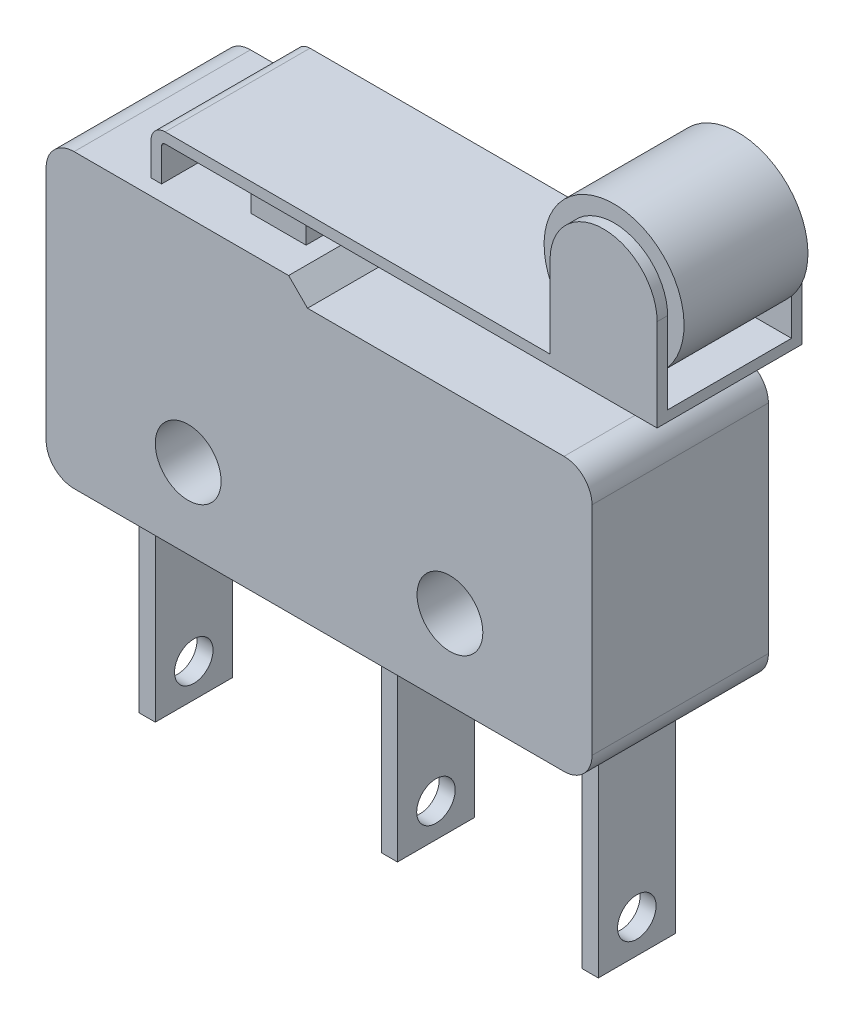
from build123d import *

# Parameters (mm, degrees)
SKETCH1_R               = 1.1938
BOSS_EXTRUDE1_DEPTH     = 6.4008
SKETCH2_W               = 1.8034
SKETCH2_H               = 7.3406
SKETCH2_W_2             = 1.27
SKETCH2_H_2             = 1.2954
SKETCH2_R               = 0.6985
SKETCH2_W_3             = 1.5494
SKETCH2_H_3             = 0.508
SKETCH2_W_4             = 0.762
CUT_EXTRUDE1_DEPTH      = 20.812
CHAMFER1_SIZE           = 0.1778
BOSS_EXTRUDE3_DEPTH     = 6.4008
SKETCH4_W               = 0.5715
SKETCH4_H               = 7.2038
CUT_EXTRUDE2_DEPTH      = 3.3876
CUT_EXTRUDE2_DEPTH_BACK = 20.812
CUT_EXTRUDE3_DEPTH      = 0.381
CUT_EXTRUDE4_DEPTH      = 0.381
CUT_EXTRUDE5_START      = -0.381
CUT_EXTRUDE5_DEPTH      = 4.4958


with BuildPart() as part:
    # Sketch1 → Boss-Extrude1 (new body)
    with BuildSketch(Plane.XY):
        with BuildLine():
            Line((8.8011, 10.5918), (9.4869, 9.906))
            Line((9.4869, 9.906), (18.796, 9.906))
            ThreePointArc((18.796, 9.906), (19.51442049, 9.60842049), (19.812, 8.89))
            Line((19.812, 8.89), (19.812, 1.016))
            ThreePointArc((19.812, 1.016), (19.51442049, 0.29757951), (18.796, 0))
            Line((18.796, 0), (18.2372, 0))
            Line((18.2372, 0), (18.2372, -7.8486))
            Line((18.2372, -7.8486), (17.653, -7.8486))
            Line((17.653, -7.8486), (17.653, 0))
            Line((17.653, 0), (10.9474, 0))
            Line((10.9474, 0), (10.9474, -7.8486))
            Line((10.9474, -7.8486), (10.3632, -7.8486))
            Line((10.3632, -7.8486), (10.3632, 0))
            Line((10.3632, 0), (2.159, 0))
            Line((2.159, 0), (2.159, -7.8486))
            Line((2.159, -7.8486), (1.5748, -7.8486))
            Line((1.5748, -7.8486), (1.5748, 0))
            Line((1.5748, 0), (1.016, 0))
            ThreePointArc((1.016, 0), (0.29757951, 0.29757951), (0, 1.016))
            Line((0, 1.016), (0, 9.5758))
            ThreePointArc((0, 9.5758), (0.29757951, 10.29422049), (1.016, 10.5918))
            Line((1.016, 10.5918), (6.1595, 10.5918))
            Line((6.1595, 10.5918), (6.1595, 11.574364795))
            ThreePointArc((6.1595, 11.574364795), (6.180021184, 11.643583736), (6.234952941, 11.690433313))
            ThreePointArc((6.234952941, 11.690433313), (7.1628, 11.8872), (8.090647059, 11.690433313))
            ThreePointArc((8.090647059, 11.690433313), (8.145578816, 11.643583736), (8.1661, 11.574364795))
            Line((8.1661, 11.574364795), (8.1661, 10.5918))
            Line((8.1661, 10.5918), (8.8011, 10.5918))
        make_face()
        with Locations((5.1562, 2.8956)):
            Circle(SKETCH1_R, mode=Mode.SUBTRACT)
        with Locations((14.6558, 2.8956)):
            Circle(SKETCH1_R, mode=Mode.SUBTRACT)
    extrude(amount=BOSS_EXTRUDE1_DEPTH)

    # Sketch2 → Cut-Extrude1 (cut, through all)
    with BuildSketch(Plane.ZY):
        with Locations((0.9017, -4.1783)):
            Rectangle(SKETCH2_W, SKETCH2_H)
        with Locations((5.4991, -4.1783)):
            Rectangle(SKETCH2_W, SKETCH2_H)
        with Locations((5.7658, 11.2395)):
            Rectangle(SKETCH2_W_2, SKETCH2_H_2)
        with Locations((3.2004, -6.4516)):
            Circle(SKETCH2_R)
        with Locations((5.6261, -0.254)):
            Rectangle(SKETCH2_W_3, SKETCH2_H_3)
        with Locations((0.7747, -0.254)):
            Rectangle(SKETCH2_W_3, SKETCH2_H_3)
        with Locations((0.381, 11.2395)):
            Rectangle(SKETCH2_W_4, SKETCH2_H_2)
    extrude(amount=-CUT_EXTRUDE1_DEPTH, mode=Mode.SUBTRACT)

    # Chamfer1
    chamfer1_edges = [part.edges().sort_by_distance(p)[0] for p in [
        (1.8669, -7.8486, 1.8034),
        (10.6553, -7.8486, 1.8034),
        (17.9451, -7.8486, 1.8034),
        (18.2372, -7.8486, 3.2004),
        (17.653, -7.8486, 3.2004),
        (10.9474, -7.8486, 3.2004),
        (10.3632, -7.8486, 3.2004),
        (2.159, -7.8486, 3.2004),
        (1.5748, -7.8486, 3.2004),
        (1.8669, -7.8486, 4.5974),
        (10.6553, -7.8486, 4.5974),
        (17.9451, -7.8486, 4.5974),
    ]]
    chamfer(chamfer1_edges, length=CHAMFER1_SIZE)

    # Sketch3 → Boss-Extrude3 (add, through all)
    with BuildSketch(Plane.XY.offset(6.4008)):
        with BuildLine():
            Line((3.2385, 10.5918), (3.2385, 11.7856))
            ThreePointArc((3.2385, 11.7856), (3.387289755, 12.144810245), (3.7465, 12.2936))
            Line((3.7465, 12.2936), (17.7165, 12.2936))
            Line((17.7165, 12.2936), (17.7165, 13.619763092))
            ThreePointArc((17.7165, 13.619763092), (19.6596, 17.7956), (21.6027, 13.619763092))
            Line((21.6027, 13.619763092), (21.6027, 12.2936))
            Line((21.6027, 12.2936), (21.6027, 11.9126))
            Line((21.6027, 11.9126), (3.7465, 11.9126))
            ThreePointArc((3.7465, 11.9126), (3.656697439, 11.875402561), (3.6195, 11.7856))
            Line((3.6195, 11.7856), (3.6195, 10.5918))
            Line((3.6195, 10.5918), (3.2385, 10.5918))
        make_face()
    extrude(amount=-BOSS_EXTRUDE3_DEPTH)

    # Sketch4 → Cut-Extrude2 (cut, two sides)
    with BuildSketch(Plane(origin=(19.812, 0, 0), x_dir=(0, 0, -1), z_dir=(1, 0, 0))) as cut_extrude2_sk:
        with Locations((-0.28575, 14.1937)):
            Rectangle(SKETCH4_W, SKETCH4_H)
        with Locations((-6.11505, 14.1937)):
            Rectangle(SKETCH4_W, SKETCH4_H)
    extrude(amount=CUT_EXTRUDE2_DEPTH, mode=Mode.SUBTRACT)
    extrude(cut_extrude2_sk.sketch, amount=-CUT_EXTRUDE2_DEPTH_BACK, mode=Mode.SUBTRACT)

    # Sketch5 → Cut-Extrude3 (cut)
    with BuildSketch(Plane.XY.offset(5.8293)):
        with BuildLine():
            Line((21.6027, 13.619763092), (21.6027, 15.2556))
            ThreePointArc((21.6027, 15.2556), (19.6596, 17.1987), (17.7165, 15.2556))
            Line((17.7165, 15.2556), (17.7165, 13.619763092))
            ThreePointArc((17.7165, 13.619763092), (19.6596, 17.7956), (21.6027, 13.619763092))
        make_face()
    extrude(amount=-CUT_EXTRUDE3_DEPTH, mode=Mode.SUBTRACT)

    # Sketch6 → Cut-Extrude4 (cut)
    with BuildSketch(Plane(origin=(0, 0, 0.5715), x_dir=(-1, 0, 0), z_dir=(0, 0, -1))):
        with BuildLine():
            Line((-21.6027, 15.2556), (-21.6027, 13.619763092))
            ThreePointArc((-21.6027, 13.619763092), (-19.6596, 17.7956), (-17.7165, 13.619763092))
            Line((-17.7165, 13.619763092), (-17.7165, 15.2556))
            ThreePointArc((-17.7165, 15.2556), (-19.6596, 17.1987), (-21.6027, 15.2556))
        make_face()
    extrude(amount=-CUT_EXTRUDE4_DEPTH, mode=Mode.SUBTRACT)

    # Sketch7 → Cut-Extrude5 (cut)
    with BuildSketch(Plane(origin=(0, 0, 0.5715), x_dir=(-1, 0, 0), z_dir=(0, 0, -1)).offset(CUT_EXTRUDE5_START)):
        with BuildLine():
            Line((-21.6027, 13.619763092), (-21.6027, 12.2936))
            Line((-21.6027, 12.2936), (-17.7165, 12.2936))
            Line((-17.7165, 12.2936), (-17.7165, 13.619763092))
            ThreePointArc((-17.7165, 13.619763092), (-19.6596, 12.7156), (-21.6027, 13.619763092))
        make_face()
    extrude(amount=-CUT_EXTRUDE5_DEPTH, mode=Mode.SUBTRACT)


solid = part.part
